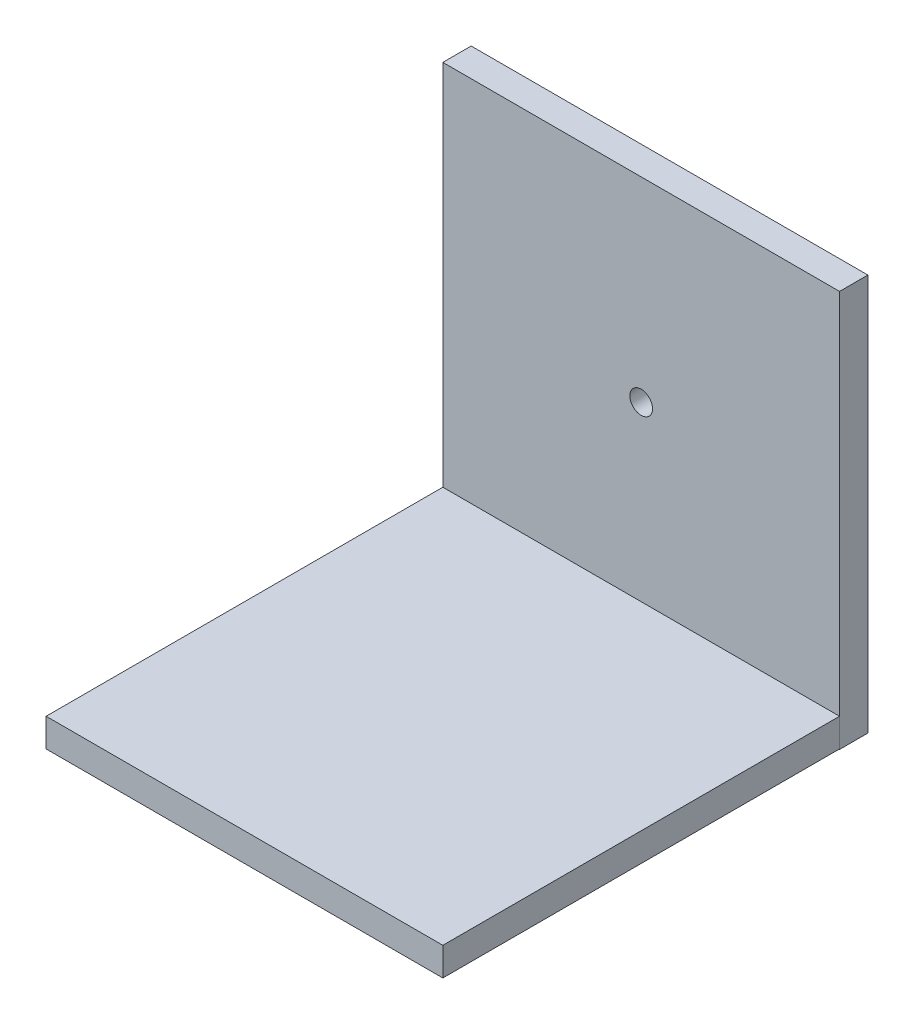
from build123d import *

# Parameters (mm, degrees)
SKETCH2_W           = 70
SKETCH2_H           = 70
BOSS_EXTRUDE1_DEPTH = 5
SKETCH1_W           = 70
SKETCH1_H           = 70
BOSS_EXTRUDE2_DEPTH = 5
SKETCH5_R           = 2
CUT_EXTRUDE1_DEPTH  = 5


with BuildPart() as part:
    # Sketch2 → Boss-Extrude1 (new body)
    with BuildSketch(Plane(origin=(0, -5.078485025, 0), x_dir=(1, 0, 0), z_dir=(0, 0, 1))):
        with Locations((35, 35)):
            Rectangle(SKETCH2_W, SKETCH2_H)
    extrude(amount=-BOSS_EXTRUDE1_DEPTH)

    # Sketch5 → Cut-Extrude1 (cut)
    with BuildSketch(Plane(origin=(0, 0, -5), x_dir=(-1, 0, 0), z_dir=(0, 0, -1))):
        with Locations((-35, 30.477465887)):
            Circle(SKETCH5_R)
    extrude(amount=-CUT_EXTRUDE1_DEPTH, mode=Mode.SUBTRACT)


with BuildPart() as body_2:
    # Sketch1 → Boss-Extrude2 (new body)
    with BuildSketch(Plane(origin=(0, 0, 0), x_dir=(1, 0, 0), z_dir=(0, 1, 0))):
        with Locations((35, -35)):
            Rectangle(SKETCH1_W, SKETCH1_H)
    extrude(amount=-BOSS_EXTRUDE2_DEPTH)


solid = Compound([part.part, body_2.part])
